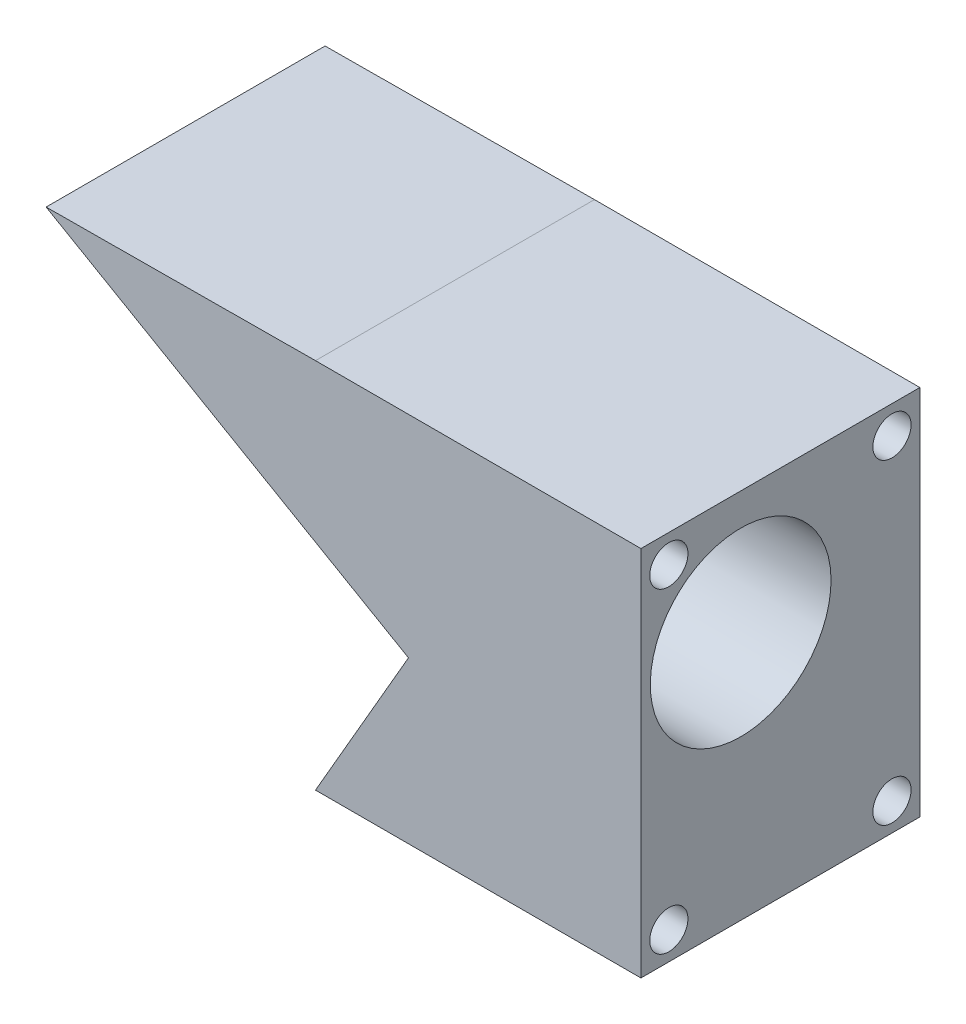
from build123d import *

# Parameters (mm, degrees)
SKETCH2_W                       = 44.45
SKETCH2_H                       = 50.8
BOSS_EXTRUDE2_DEPTH             = 38.1
F_5_0_2055_DIAMETER_HOLE1_D     = 5.2197
F_5_0_2055_DIAMETER_HOLE1_DEPTH = 12.7
F_5_0_2055_DIAMETER_HOLE1_TIP   = 1.568156087
BOSS_EXTRUDE3_DEPTH             = 38.1
CUT_EXTRUDE2_DEPTH              = 39.1
SKETCH3_R                       = 12.342015131
CUT_EXTRUDE1_DEPTH              = 1
CUT_EXTRUDE1_DEPTH_BACK         = 82.243351826


with BuildPart() as part:
    # Sketch2 → Boss-Extrude2 (new body)
    with BuildSketch(Plane.XY):
        with Locations((-18.295089844, 0.954798727)):
            Rectangle(SKETCH2_W, SKETCH2_H)
    extrude(amount=BOSS_EXTRUDE2_DEPTH)

    # #5 (0.2055) Diameter Hole1
    with Locations(Plane(origin=(3.929910156, 22.544798727, 34.29), x_dir=(0, 1, 0), z_dir=(1, 0, 0))):
        with Locations((0, 0), (0, -30.48), (-43.18, -30.48), (-43.18, 0)):
            Hole(F_5_0_2055_DIAMETER_HOLE1_D / 2, depth=F_5_0_2055_DIAMETER_HOLE1_DEPTH)
            with Locations((0, 0, -(F_5_0_2055_DIAMETER_HOLE1_DEPTH + F_5_0_2055_DIAMETER_HOLE1_TIP / 2))):  # 118° drill point
                Cone(0, F_5_0_2055_DIAMETER_HOLE1_D / 2, F_5_0_2055_DIAMETER_HOLE1_TIP, mode=Mode.SUBTRACT)

    # Sketch6 → Boss-Extrude3 (add)
    with BuildSketch(Plane(origin=(0, 0, 0), x_dir=(-1, 0, 0), z_dir=(0, 0, -1))):
        Polygon((40.520089844, 26.354798727), (77.31344167, 26.126843983), (40.520089844, 4.884192402), align=None)
    extrude(amount=-BOSS_EXTRUDE3_DEPTH)

    # Sketch7 → Cut-Extrude2 (cut, through all)
    with BuildSketch(Plane(origin=(0, 0, 0), x_dir=(-1, 0, 0), z_dir=(0, 0, -1))):
        Polygon((40.520089844, 4.884192402), (27.820089844, -2.448156017), (40.520089844, -24.445201273), align=None)
    extrude(amount=-CUT_EXTRUDE2_DEPTH, mode=Mode.SUBTRACT)

    # Sketch3 → Cut-Extrude1 (cut, two sides)
    with BuildSketch(Plane(origin=(3.929910156, 0, 0), x_dir=(0, 0, -1), z_dir=(1, 0, 0))) as cut_extrude1_sk:
        with Locations((-24.476370381, 9.6189509)):
            Circle(SKETCH3_R)
    extrude(amount=CUT_EXTRUDE1_DEPTH, mode=Mode.SUBTRACT)
    extrude(cut_extrude1_sk.sketch, amount=-CUT_EXTRUDE1_DEPTH_BACK, mode=Mode.SUBTRACT)


solid = part.part
